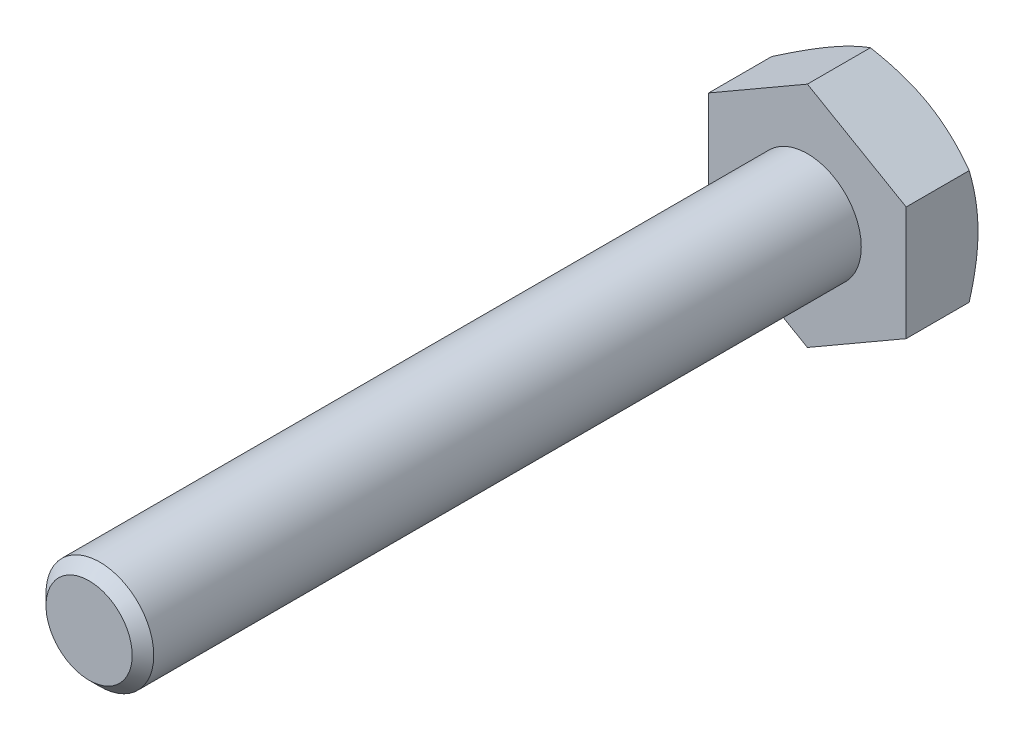
from build123d import *

# Parameters (mm, degrees)
ESQUISSE1_W        = 1.5
ESQUISSE1_H        = 20
CHANFREIN1_SIZE    = 0.3
BOSS_EXTRU_1_DEPTH = 2


with BuildPart() as part:
    # Esquisse1 → Base-R_volution (revolve)
    with BuildSketch(Plane(origin=(0, 0, 0), x_dir=(1, 0, 0), z_dir=(0, 1, 0))):
        with Locations((0.75, -10)):
            Rectangle(ESQUISSE1_W, ESQUISSE1_H)
    revolve(axis=Axis((0, 0, 0), (0, 0, 1)))

    # Chanfrein1
    chanfrein1_edges = [part.edges().sort_by_distance(p)[0] for p in [
        (-1.5, 0, 20),
    ]]
    chamfer(chanfrein1_edges, length=CHANFREIN1_SIZE)

    # Esquisse6 → Boss.-Extru.1 (add)
    with BuildSketch(Plane.XY):
        Polygon((2.75, -1.58771324), (2.75, 1.58771324), (0, 3.175426481), (-2.75, 1.58771324), (-2.75, -1.58771324), (0, -3.175426481), align=None)
    extrude(amount=-BOSS_EXTRU_1_DEPTH)

    # Esquisse7 → Enl_vement de mati_re-R_volution1 (revolve, cut)
    with BuildSketch(Plane(origin=(0, 0, 0), x_dir=(1, 0, 0), z_dir=(0, 1, 0)), mode=Mode.PRIVATE) as enl_vement_de_mati_re_r_volution1_sk:
        Polygon((-2.75, 2), (-6.214101615, 2), (-6.214101615, 0), align=None)
    revolve(enl_vement_de_mati_re_r_volution1_sk.sketch.rotate(Axis((0, 0, -6.239446496), (0, 0, 1)), 180), axis=Axis((0, 0, -6.239446496), (0, 0, 1)), mode=Mode.SUBTRACT)  # turned: the seam where the file's is


solid = part.part
